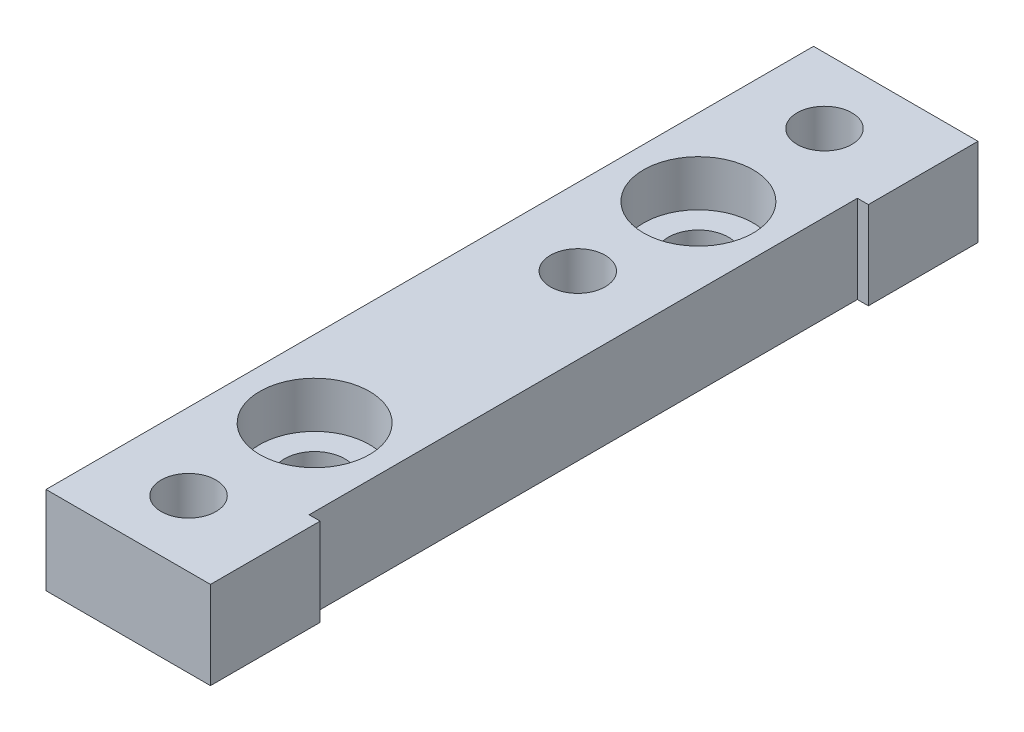
from build123d import *

# Parameters (mm, degrees)
SKETCH1_W           = 15
SKETCH1_H           = 70
BOSS_EXTRUDE1_DEPTH = 8
SKETCH2_W           = 1
SKETCH2_H           = 50
CUT_EXTRUDE1_DEPTH  = 8
SKETCH3_R           = 2.5
CUT_EXTRUDE2_DEPTH  = 8
SKETCH4_R           = 2.75
CUT_EXTRUDE3_DEPTH  = 8
SKETCH5_R           = 5
CUT_EXTRUDE4_DEPTH  = 4.2
SKETCH6_R           = 2.5
CUT_EXTRUDE5_DEPTH  = 72.2


with BuildPart() as part:
    # Sketch1 → Boss-Extrude1 (new body)
    with BuildSketch(Plane(origin=(0, 0, 0), x_dir=(1, 0, 0), z_dir=(0, 1, 0))):
        Rectangle(SKETCH1_W, SKETCH1_H)
    extrude(amount=BOSS_EXTRUDE1_DEPTH)

    # Sketch2 → Cut-Extrude1 (cut)
    with BuildSketch(Plane(origin=(0, 8, 0), x_dir=(1, 0, 0), z_dir=(0, 1, 0))):
        with Locations((7, 0)):
            Rectangle(SKETCH2_W, SKETCH2_H)
    extrude(amount=-CUT_EXTRUDE1_DEPTH, mode=Mode.SUBTRACT)

    # Sketch3 → Cut-Extrude2 (cut)
    with BuildSketch(Plane(origin=(0, 8, 0), x_dir=(1, 0, 0), z_dir=(0, 1, 0))):
        with Locations((-0.5, -29)):
            Circle(SKETCH3_R)
        with Locations((-0.5, 29)):
            Circle(SKETCH3_R)
    extrude(amount=-CUT_EXTRUDE2_DEPTH, mode=Mode.SUBTRACT)

    # Sketch4 → Cut-Extrude3 (cut)
    with BuildSketch(Plane(origin=(0, 8, 0), x_dir=(1, 0, 0), z_dir=(0, 1, 0))):
        with Locations((-0.5, -17.5)):
            Circle(SKETCH4_R)
        with Locations((-0.5, 17.5)):
            Circle(SKETCH4_R)
    extrude(amount=-CUT_EXTRUDE3_DEPTH, mode=Mode.SUBTRACT)

    # Sketch5 → Cut-Extrude4 (cut)
    with BuildSketch(Plane(origin=(0, 8, 0), x_dir=(1, 0, 0), z_dir=(0, 1, 0))):
        with Locations((-0.5, 17.5)):
            Circle(SKETCH5_R)
        with Locations((-0.5, -17.5)):
            Circle(SKETCH5_R)
    extrude(amount=-CUT_EXTRUDE4_DEPTH, mode=Mode.SUBTRACT)

    # Sketch6 → Cut-Extrude5 (cut)
    with BuildSketch(Plane(origin=(0, 8, 0), x_dir=(1, 0, 0), z_dir=(0, 1, 0))):
        with Locations((-0.5, 6.5)):
            Circle(SKETCH6_R)
    extrude(amount=-CUT_EXTRUDE5_DEPTH, mode=Mode.SUBTRACT)


solid = part.part
